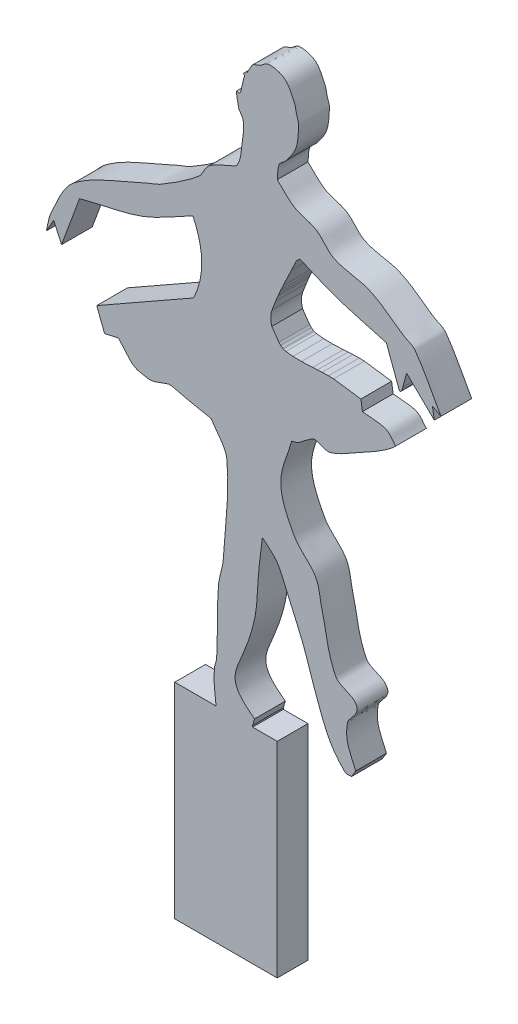
from build123d import *

# Parameters (mm, degrees)
SALIENTE_EXTRUIR3_DEPTH = 3


with BuildPart() as part:
    # Croquis4 → Saliente-Extruir3 (new body)
    with BuildSketch(Plane.XY):
        with BuildLine():
            Line((1101.730393348, -9981.645215457), (1102.561376185, -9982.099742779))
            add(Edge.make_bspline(
                [(1086.585583073, -9970.089301656), (1087.144799379, -9970.584970655), (1087.627035062, -9971.184308524), (1088.263231991, -9971.576308653), (1088.904195881, -9971.971245999), (1089.719754559, -9972.019506341), (1090.36029314, -9972.415133112), (1091.034709986, -9972.831684693), (1091.438263352, -9973.634207822), (1092.152327212, -9973.978396877), (1093.24687657, -9974.505985416), (1094.556544402, -9974.461337553), (1095.660138588, -9974.969734874), (1096.844793149, -9975.515474616), (1097.842327734, -9976.39912404), (1098.939179656, -9977.104924407), (1099.303980251, -9977.33966566), (1099.790232016, -9977.440057712), (1100.044902807, -9977.791235329), (1101.02131111, -9979.137650988), (1101.722551726, -9980.663573629), (1102.561376185, -9982.099742779)],
                knots=[0, 0, 0, 0, 1, 1, 1, 2, 2, 2, 3, 3, 3, 4, 4, 4, 5, 5, 5, 6, 6, 6, 7, 7, 7, 7], degree=3))
            add(Edge.make_bspline(
                [(1083.649697466, -9962.501753135), (1083.759149271, -9962.255486574), (1083.997757004, -9961.795626983), (1084.18349485, -9961.586671906), (1084.297509352, -9961.458405592), (1084.775409564, -9961.341032432), (1084.94606254, -9961.243516446), (1085.228046953, -9961.082382496), (1085.460153377, -9960.753085086), (1085.784887, -9960.747847447), (1086.315580671, -9960.739287872), (1086.898671374, -9960.869978779), (1087.310022381, -9961.205388062), (1087.783030915, -9961.591071943), (1087.997400938, -9962.219267646), (1088.263231994, -9962.768651828), (1088.382732301, -9963.01561913), (1088.388726389, -9963.302835292), (1088.453873916, -9963.569347903), (1088.528532662, -9963.874770043), (1088.697599406, -9964.170370292), (1088.682644223, -9964.484429131), (1088.593636412, -9966.353593154), (1088.485588195, -9966.725977239), (1087.462535917, -9968.030368892), (1087.26287259, -9968.284939634), (1086.903004157, -9968.41902439), (1086.776224996, -9968.716679813), (1086.595211155, -9969.141668829), (1086.64913038, -9969.631761042), (1086.585583073, -9970.089301656)],
                knots=[0, 0, 0, 0, 1, 1, 1, 2, 2, 2, 3, 3, 3, 4, 4, 4, 5, 5, 5, 6, 6, 6, 7, 7, 7, 8, 8, 8, 9, 9, 9, 10, 10, 10, 10], degree=3))
            Line((1083.649697466, -9962.501753135), (1083.573440697, -9962.46362475))
            Line((1083.573440697, -9962.46362475), (1083.306542005, -9962.730523442))
            Line((1083.306542005, -9962.730523442), (1083.402831653, -9962.94717515))
            add(Edge.make_bspline(
                [(1064.051707825, -9985.683810921), (1064.220717482, -9985.058566797), (1064.269208557, -9984.387447065), (1064.558736795, -9983.808078548), (1065.179674498, -9982.565533925), (1065.659282687, -9981.118440151), (1066.757924906, -9980.268460126), (1068.745119902, -9978.731038733), (1071.237970545, -9977.992029999), (1073.497198014, -9976.892712149), (1074.091471051, -9976.603544739), (1074.749483819, -9976.443953628), (1075.316269765, -9976.104053753), (1076.558743338, -9975.358945983), (1077.791945253, -9974.579298488), (1078.903749629, -9973.650418948), (1079.342653552, -9973.283727756), (1079.474433396, -9972.629732782), (1079.913484273, -9972.263217556), (1080.428374839, -9971.833392124), (1081.103426575, -9971.643773345), (1081.692250815, -9971.322606393), (1082.036876203, -9971.134634707), (1082.523565397, -9971.079603027), (1082.713434248, -9970.736019221), (1083.06084799, -9970.107344561), (1083.080009924, -9969.3435032), (1083.17906765, -9968.632085108), (1083.265113398, -9968.01411713), (1083.350903864, -9967.380575077), (1083.266727267, -9966.762349719), (1083.21917776, -9966.413127826), (1082.862514928, -9966.161814114), (1082.795603915, -9965.815779718), (1082.360023651, -9963.563149752), (1082.768661412, -9965.223327482), (1083.041758464, -9964.363232961), (1083.189176613, -9963.898952804), (1083.191236002, -9963.385940982), (1083.402831653, -9962.94717515)],
                knots=[0, 0, 0, 0, 1, 1, 1, 2, 2, 2, 3, 3, 3, 4, 4, 4, 5, 5, 5, 6, 6, 6, 7, 7, 7, 8, 8, 8, 9, 9, 9, 10, 10, 10, 11, 11, 11, 12, 12, 12, 13, 13, 13, 13], degree=3))
            Line((1064.051707825, -9985.683810921), (1064.776147131, -9984.425574232))
            Line((1064.776147131, -9984.425574232), (1065.538714821, -9986.103223151))
            Line((1065.538714821, -9986.103223151), (1067.292620509, -9981.337175086))
            add(Edge.make_bspline(
                [(1078.349852019, -9977.257437943), (1076.735750407, -9978.083552941), (1075.200792384, -9979.087160784), (1073.507547185, -9979.735782937), (1071.509796682, -9980.501050266), (1069.34961693, -9980.749461823), (1067.292620509, -9981.337175086)],
                knots=[0, 0, 0, 0, 1, 1, 1, 2, 2, 2, 2], degree=3))
            add(Edge.make_bspline(
                [(1078.426108788, -9984.15867554), (1080.051236174, -9980.793124775), (1078.349852019, -9977.257437943)],
                knots=[0, 0, 0, 0.498057367, 0.498057367, 0.498057367], degree=2))
            Line((1078.426108788, -9984.15867554), (1068.970269428, -9989.534777757))
            Line((1068.970269428, -9989.534777757), (1069.732837118, -9991.517453752))
            Line((1069.732837118, -9991.517453752), (1071.10545896, -9991.212426676))
            add(Edge.make_bspline(
                [(1080.141886091, -9993.500129747), (1079.191772103, -9993.332462573), (1078.261657792, -9993.132828361), (1077.320385637, -9992.928203979), (1076.889270147, -9992.834483221), (1076.46489171, -9992.644668641), (1076.024020563, -9992.661305288), (1075.726929662, -9992.672516265), (1074.604756679, -9993.311406104), (1073.965087799, -9993.195102671), (1073.497882739, -9993.110156296), (1072.98270857, -9993.084387038), (1072.592465957, -9992.813818826), (1071.993834314, -9992.398767553), (1071.601127959, -9991.746224059), (1071.10545896, -9991.212426676)],
                knots=[0, 0, 0, 0, 1, 1, 1, 2, 2, 2, 3, 3, 3, 4, 4, 4, 5, 5, 5, 5], degree=3))
            add(Edge.make_bspline(
                [(1080.599426705, -10017.368498454), (1080.458520781, -10016.335188345), (1080.342546088, -10015.275063033), (1080.485041552, -10014.241970924), (1080.520842225, -10013.982416042), (1080.662526294, -10013.741084936), (1080.675683474, -10013.479403234), (1080.777192084, -10011.460509767), (1080.712324094, -10009.435110085), (1080.828197012, -10007.416990096), (1080.880066096, -10006.513603547), (1081.272243117, -10005.651403829), (1081.323866011, -10004.748003179), (1081.487137698, -10001.890748655), (1081.966118248, -9999.015360183), (1081.667021472, -9996.169116663), (1081.559933983, -9995.150058301), (1080.650264551, -9994.389792052), (1080.141886091, -9993.500129747)],
                knots=[0, 0, 0, 0, 1, 1, 1, 2, 2, 2, 3, 3, 3, 4, 4, 4, 5, 5, 5, 6, 6, 6, 6], degree=3))
            Line((1080.599426705, -10017.368498454), (1080.627246798, -10017.549329058))
            Line((1080.627246798, -10017.549329058), (1076.585583073, -10017.549329058))
            Line((1076.585583073, -10017.549329058), (1076.585583073, -10037.549329058))
            Line((1076.585583073, -10037.549329058), (1086.585583073, -10037.549329058))
            Line((1086.585583073, -10037.549329058), (1086.585583073, -10017.549329058))
            Line((1086.585583073, -10017.549329058), (1084.184344317, -10017.549329058))
            Line((1084.184344317, -10017.549329058), (1084.184344317, -10017.405815596))
            Line((1084.184344317, -10017.405815596), (1084.37498624, -10016.757633059))
            add(Edge.make_bspline(
                [(1085.13755393, -10001.048738639), (1085.023168777, -10001.98923879), (1084.893066396, -10002.927960398), (1084.794398469, -10003.870239093), (1084.638854692, -10005.355682165), (1084.693365021, -10006.872024001), (1084.37498624, -10008.331260081), (1083.225212051, -10013.601058445), (1080.734087743, -10014.06067121), (1084.37498624, -10016.757633059)],
                knots=[0, 0, 0, 0, 1, 1, 1, 2, 2, 2, 3, 3, 3, 3], degree=3))
            add(Edge.make_bspline(
                [(1093.8308256, -10016.910146598), (1093.614764754, -10016.884727675), (1093.337783941, -10016.9864012), (1093.182643063, -10016.833889828), (1091.726656924, -10015.40258142), (1091.293252158, -10014.186570359), (1090.589912916, -10012.334740456), (1089.889001118, -10010.489301799), (1089.388354535, -10008.564035619), (1088.569108537, -10006.767996316), (1086.402775715, -10002.018728207), (1087.081219441, -10002.693378687), (1085.13755393, -10001.048738639)],
                knots=[0, 0, 0, 0, 1, 1, 1, 2, 2, 2, 3, 3, 3, 4, 4, 4, 4], degree=3))
            Line((1093.8308256, -10016.910146598), (1094.25023783, -10016.223835676))
            add(Edge.make_bspline(
                [(1087.997182769, -9991.478514125), (1087.641317847, -9992.851135968), (1086.888304472, -9994.178978427), (1086.929588002, -9995.596379653), (1086.967970495, -9996.914178581), (1087.591159417, -9998.177494226), (1088.225953076, -9999.332961335), (1088.742365803, -10000.272948547), (1089.796504625, -10000.838808797), (1090.323014224, -10001.773177944), (1090.722524293, -10002.482167644), (1090.72616077, -10003.350077475), (1090.933068377, -10004.137137785), (1091.374346405, -10005.815724795), (1091.47633405, -10007.625306485), (1092.267561835, -10009.170084541), (1092.606643294, -10009.832100722), (1093.624574355, -10009.849974242), (1094.135852676, -10010.390192845), (1094.932129368, -10011.231541802), (1093.565593216, -10011.945125074), (1093.449541755, -10012.525382378), (1093.132073965, -10014.112721329), (1093.67794881, -10014.910937337), (1094.25023783, -10016.223835676)],
                knots=[0, 0, 0, 0, 1, 1, 1, 2, 2, 2, 3, 3, 3, 4, 4, 4, 5, 5, 5, 6, 6, 6, 7, 7, 7, 8, 8, 8, 8], degree=3))
            add(Edge.make_bspline(
                [(1098.13933305, -9986.826851214), (1097.427795919, -9987.597683106), (1095.405780397, -9988.721620543), (1094.440879752, -9989.228939439), (1093.540299299, -9989.702440501), (1092.685250493, -9990.326976352), (1091.695636067, -9990.563432897), (1091.132679023, -9990.697944757), (1090.461452805, -9989.975471511), (1089.979858764, -9990.296534205), (1088.195949516, -9991.485807037), (1089.158169965, -9991.146803498), (1087.997182769, -9991.478514125)],
                knots=[0, 0, 0, 0, 1, 1, 1, 2, 2, 2, 3, 3, 3, 4, 4, 4, 4], degree=3))
            add(Edge.make_bspline(
                [(1094.898420366, -9985.53048614), (1095.660988057, -9985.644871294), (1096.470176123, -9985.587262675), (1097.186123437, -9985.873641601), (1097.603331951, -9986.040525006), (1097.821596513, -9986.509114676), (1098.13933305, -9986.826851214)],
                knots=[0, 0, 0, 0, 1, 1, 1, 2, 2, 2, 2], degree=3))
            Line((1094.898420366, -9985.53048614), (1094.745906828, -9984.539148143))
            Line((1094.745906828, -9984.539148143), (1092.091521127, -9984.168477275))
            Line((1092.091521127, -9984.168477275), (1091.587528573, -9984.156593454))
            Line((1091.587528573, -9984.156593454), (1090.959511365, -9984.173040557))
            Line((1090.959511365, -9984.173040557), (1090.510444401, -9984.196602654))
            Line((1090.510444401, -9984.196602654), (1090.040912877, -9984.225142095))
            Line((1090.040912877, -9984.225142095), (1088.941909627, -9984.27319755))
            Line((1088.941909627, -9984.27319755), (1088.11724264, -9984.253752431))
            Line((1088.11724264, -9984.253752431), (1087.434696217, -9984.173273624))
            Line((1087.434696217, -9984.173273624), (1087.195075368, -9984.111343576))
            Line((1087.195075368, -9984.111343576), (1087.112748298, -9984.071028284))
            Line((1087.112748298, -9984.071028284), (1086.920421304, -9983.930750722))
            Line((1086.920421304, -9983.930750722), (1086.752390043, -9983.752833572))
            Line((1086.752390043, -9983.752833572), (1086.056693205, -9982.747114071))
            add(Edge.make_bspline(
                [(1086.056693205, -9982.747114071), (1085.834060109, -9982.001398478), (1086.080477966, -9981.337175086)],
                knots=[0, 0, 0, 1, 1, 1], degree=2))
            Line((1086.080477966, -9981.337175086), (1086.431008388, -9980.418287746))
            Line((1086.431008388, -9980.418287746), (1086.658786043, -9979.871473739))
            Line((1086.658786043, -9979.871473739), (1086.784980452, -9979.580304244))
            Line((1086.784980452, -9979.580304244), (1086.94603282, -9979.218145314))
            Line((1086.94603282, -9979.218145314), (1087.16605149, -9978.73662482))
            Line((1087.16605149, -9978.73662482), (1087.97379349, -9977.032685367))
            Line((1087.97379349, -9977.032685367), (1088.462336796, -9975.996814223))
            Line((1088.462336796, -9975.996814223), (1088.800425745, -9975.677511039))
            add(Edge.make_bspline(
                [(1092.835296363, -9977.29773343), (1092.635947892, -9977.233444736), (1092.437265782, -9977.167066956), (1092.239397599, -9977.098137465), (1091.068069067, -9976.69009269), (1089.938326008, -9976.173118314), (1088.800425745, -9975.677511039)],
                knots=[0.879133605, 0.879133605, 0.879133605, 0.879133605, 1, 1, 1, 1.797436755, 1.797436755, 1.797436755, 1.797436755], degree=3))
            Line((1092.835296363, -9977.29773343), (1094.619892522, -9977.825895853))
            Line((1094.619892522, -9977.825895853), (1095.768969479, -9978.139294765))
            add(Edge.make_bspline(
                [(1097.23421597, -9978.547016077), (1096.747485272, -9978.405827019), (1096.258373766, -9978.272101947), (1095.768969479, -9978.139294765)],
                knots=[0, 0, 0, 0, 0.29234138, 0.29234138, 0.29234138, 0.29234138], degree=3))
            Line((1097.23421597, -9978.547016077), (1098.483074605, -9981.905735315))
            add(Edge.make_bspline(
                [(1098.483074605, -9981.905735315), (1098.5936536, -9982.096410001), (1098.713051304, -9981.959335841), (1098.841267718, -9981.494512836)],
                knots=[0.232918263, 0.232918263, 0.232918263, 0.232918263, 1, 1, 1, 1], degree=3))
            Line((1098.841267718, -9981.494512836), (1099.206927817, -9980.116255539))
            Line((1099.206927817, -9980.116255539), (1101.914043117, -9982.747114071))
            Line((1101.914043117, -9982.747114071), (1101.730393348, -9981.645215457))
        make_face()
    extrude(amount=SALIENTE_EXTRUIR3_DEPTH)


solid = part.part
